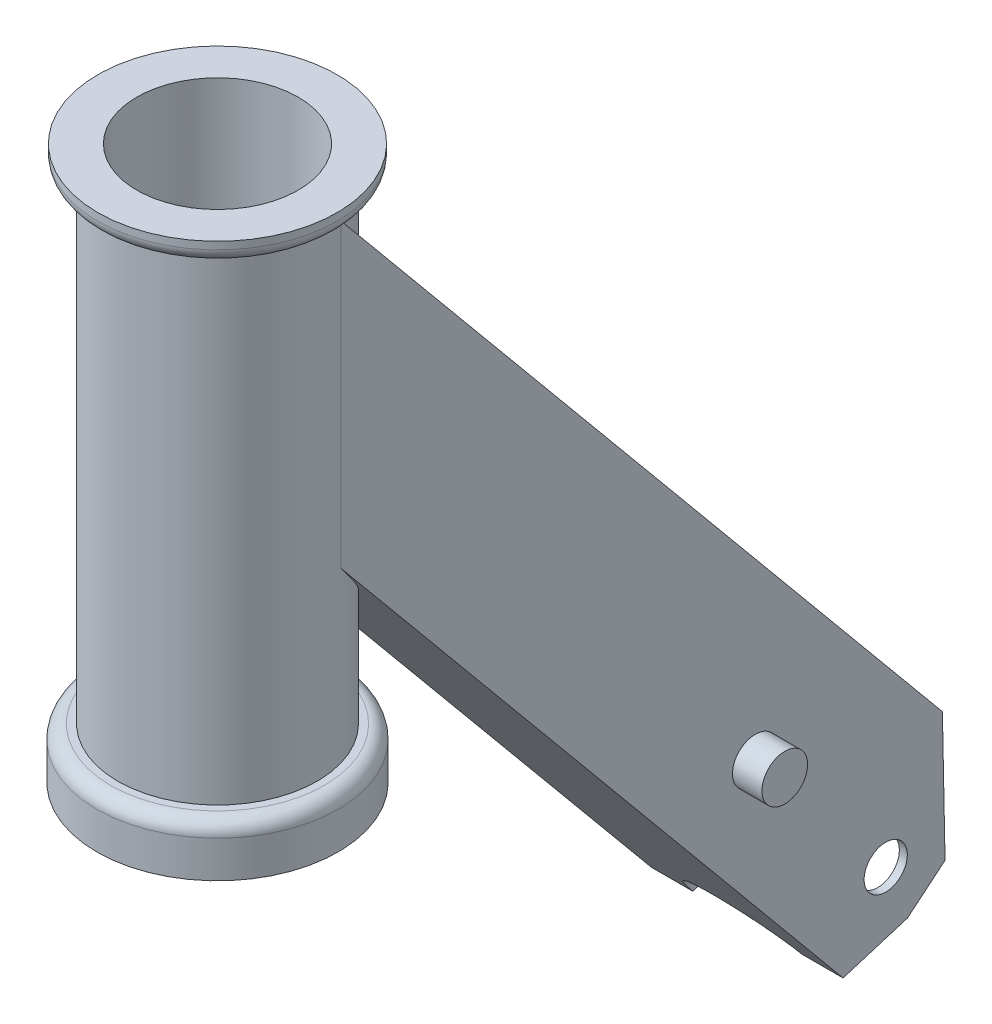
from build123d import *

# Parameters (mm, degrees)
SKETCH4_R           = 3.96875
BOSS_EXTRUDE1_DEPTH = 17.5895
SKETCH5_W           = 32.258
SKETCH5_H           = 32.3469
CUT_EXTRUDE1_DEPTH  = 149.479
CUT_EXTRUDE2_REACH  = 129.277
CUT_EXTRUDE3_REACH  = 126.564
SKETCH8_R           = 4.19735
BOSS_EXTRUDE2_DEPTH = 5.4102
SKETCH9_R           = 14.8209
CUT_EXTRUDE4_DEPTH  = 102.6


with BuildPart() as part:
    # Sketch3 → Revolve1 (revolve)
    with BuildSketch(Plane.XY):
        with BuildLine():
            Line((0, 0), (22.1742, 0))
            Line((22.1742, 0), (22.1742, 6.7818))
            ThreePointArc((22.1742, 6.7818), (21.430251224, 8.577851224), (19.6342, 9.3218))
            Line((19.6342, 9.3218), (18.3134, 9.3218))
            Line((18.3134, 9.3218), (18.3134, 97.6884))
            Line((18.3134, 97.6884), (19.431, 97.6884))
            ThreePointArc((19.431, 97.6884), (21.227051224, 98.432348776), (21.971, 100.2284))
            Line((21.971, 100.2284), (21.971, 101.6))
            Line((21.971, 101.6), (0, 101.6))
            Line((0, 101.6), (0, 0))
        make_face()
    revolve(axis=Axis((0, 101.6, 0), (0, -1, 0)))

    # Sketch4 → Boss-Extrude1 (add, symmetric)
    with BuildSketch(Plane(origin=(0, 0, 0), x_dir=(0, 0, -1), z_dir=(1, 0, 0))):
        Polygon((3.319704812, 97.6884), (115.572791881, -37.744541555), (116.058945734, -61.655625383), (109.136154682, -67.393554854), (97.331039415, -71.002358659), (0, 46.427186637), align=None)
        with Locations((105.157137902, -57.289139694)):
            Circle(SKETCH4_R, mode=Mode.SUBTRACT)
    extrude(amount=BOSS_EXTRUDE1_DEPTH, both=True)

    # Sketch5 → Cut-Extrude1 (cut)
    with BuildSketch(Plane(origin=(0, -93.569618845, -77.554828616), x_dir=(1, 0, 0), z_dir=(0, -0.769917596, -0.638143319))):
        with Locations((0, -47.261148993)):
            Rectangle(SKETCH5_W, SKETCH5_H)
    extrude(amount=-CUT_EXTRUDE1_DEPTH, mode=Mode.SUBTRACT)

    # Sketch6 → Cut-Extrude2 (cut, up to next)
    with BuildSketch(Plane(origin=(0, 41.412373886, -49.963878576), x_dir=(-1, 0, 0), z_dir=(0, 0.638143319, -0.769917596)), mode=Mode.PRIVATE) as cut_extrude2_sk1:
        with BuildLine():
            Line((14.9225, -97.744891724), (14.9225, -112.907394914))
            Line((14.9225, -112.907394914), (-14.9225, -112.907394914))
            Line((-14.9225, -112.907394914), (-14.9225, -97.744891724))
            ThreePointArc((-14.9225, -97.744891724), (0, -82.822391724), (14.9225, -97.744891724))
        make_face()
    cut_extrude2_tool1 = extrude(cut_extrude2_sk1.sketch, amount=-CUT_EXTRUDE2_REACH, mode=Mode.PRIVATE) & part.part
    add(cut_extrude2_tool1.solids().sort_by_distance((0, -35.009466, -113.305835))[0], mode=Mode.SUBTRACT)

    # Sketch7 → Cut-Extrude3 (cut, up to next)
    with BuildSketch(Plane(origin=(0, 18.906399111, -22.81050181), x_dir=(1, 0, 0), z_dir=(0, -0.638143319, 0.769917596)), mode=Mode.PRIVATE) as cut_extrude3_sk1:
        with BuildLine():
            Line((-9.989016296, -117.386717047), (9.989016296, -117.386717047))
            ThreePointArc((9.989016296, -117.386717047), (0, -106.76951783), (-9.989016296, -117.386717047))
        make_face()
    cut_extrude3_tool1 = extrude(cut_extrude3_sk1.sketch, amount=-CUT_EXTRUDE3_REACH, mode=Mode.PRIVATE) & part.part
    add(cut_extrude3_tool1.solids().sort_by_distance((0, -67.984352, -94.829576))[0], mode=Mode.SUBTRACT)

    # Sketch8 → Boss-Extrude2 (add)
    with BuildSketch(Plane(origin=(17.5895, 0, 0), x_dir=(0, 0, -1), z_dir=(1, 0, 0))):
        with Locations((81.207034429, -28.363574673)):
            Circle(SKETCH8_R)
    boss_extrude2 = extrude(amount=BOSS_EXTRUDE2_DEPTH)

    # Mirror1: Boss-Extrude2 across plane
    add(boss_extrude2.mirror(Plane(origin=(0, 0, 0), x_dir=(0, 0, 1), z_dir=(1, 0, 0))))

    # Sketch9 → Cut-Extrude4 (cut, through all)
    with BuildSketch(Plane.XZ):
        Circle(SKETCH9_R)
    extrude(amount=-CUT_EXTRUDE4_DEPTH, mode=Mode.SUBTRACT)


solid = part.part
